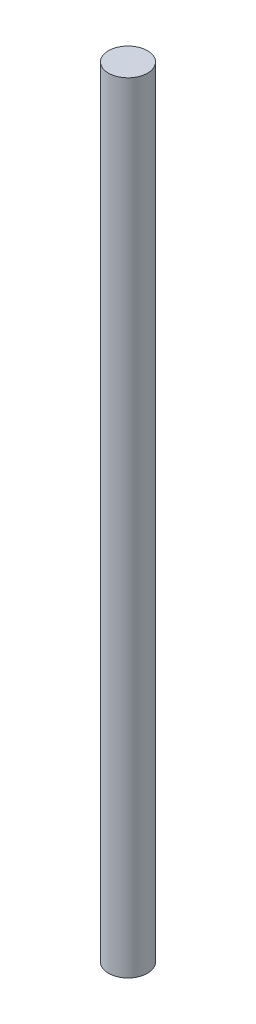
from build123d import *

# Parameters (mm, degrees)
SKETCH_1_R      = 7.5
EXTRUDE_1_DEPTH = 300


with BuildPart() as part:
    # 草图1 → 凸台-拉伸1 (new body)
    with BuildSketch(Plane(origin=(0, 0, 0), x_dir=(1, 0, 0), z_dir=(0, 1, 0))):
        Circle(SKETCH_1_R)
    extrude(amount=EXTRUDE_1_DEPTH)


solid = part.part
